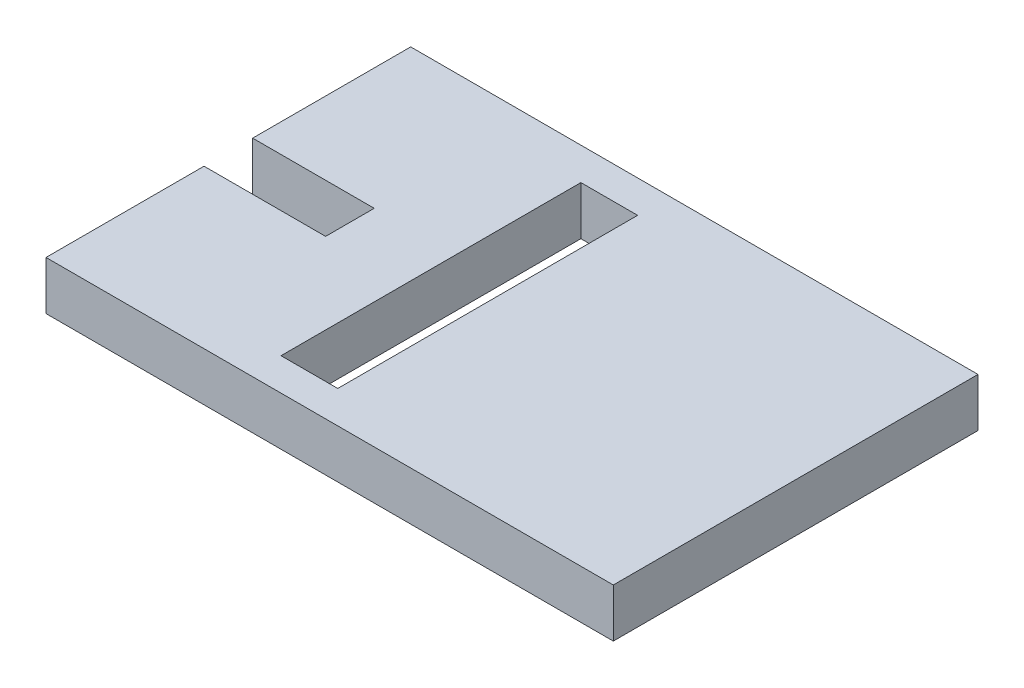
from build123d import *

# Parameters (mm, degrees)
SKETCH_1_W      = 7
SKETCH_1_H      = 37
EXTRUDE_1_DEPTH = 6


with BuildPart() as part:
    # Эскиз1 → Бобышка-Вытянуть1 (new body)
    with BuildSketch(Plane(origin=(0, 0, 0), x_dir=(1, 0, 0), z_dir=(0, 1, 0))):
        Polygon((-35, 3), (-35, 22.5), (35, 22.5), (35, -22.5), (-35, -22.5), (-35, -3), (-20, -3), (-20, 3), align=None)
        with Locations((-6.5, 0)):
            Rectangle(SKETCH_1_W, SKETCH_1_H, mode=Mode.SUBTRACT)
    extrude(amount=EXTRUDE_1_DEPTH)


solid = part.part
